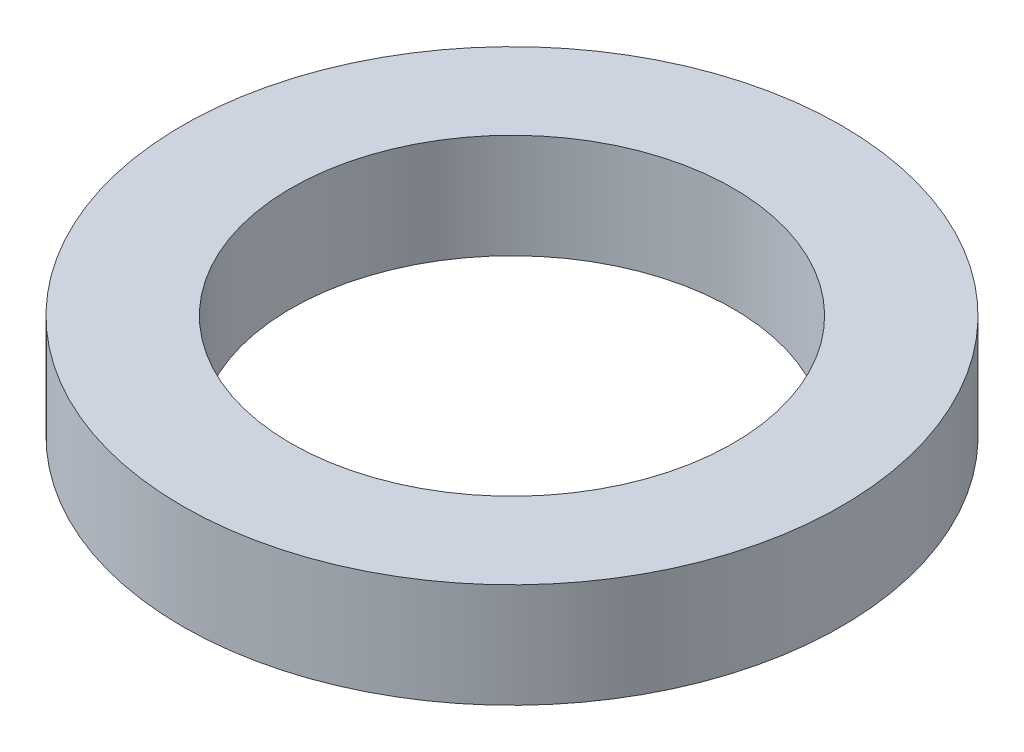
from build123d import *

# Parameters (mm, degrees)
CROQUIS1_R              = 6
CROQUIS1_R_2            = 4.025
SALIENTE_EXTRUIR1_DEPTH = 0.95


with BuildPart() as part:
    # Croquis1 → Saliente-Extruir1 (new body, symmetric)
    with BuildSketch(Plane(origin=(0, 0, 0), x_dir=(1, 0, 0), z_dir=(0, 1, 0))):
        Circle(CROQUIS1_R)
        Circle(CROQUIS1_R_2, mode=Mode.SUBTRACT)
    extrude(amount=SALIENTE_EXTRUIR1_DEPTH, both=True)


solid = part.part
